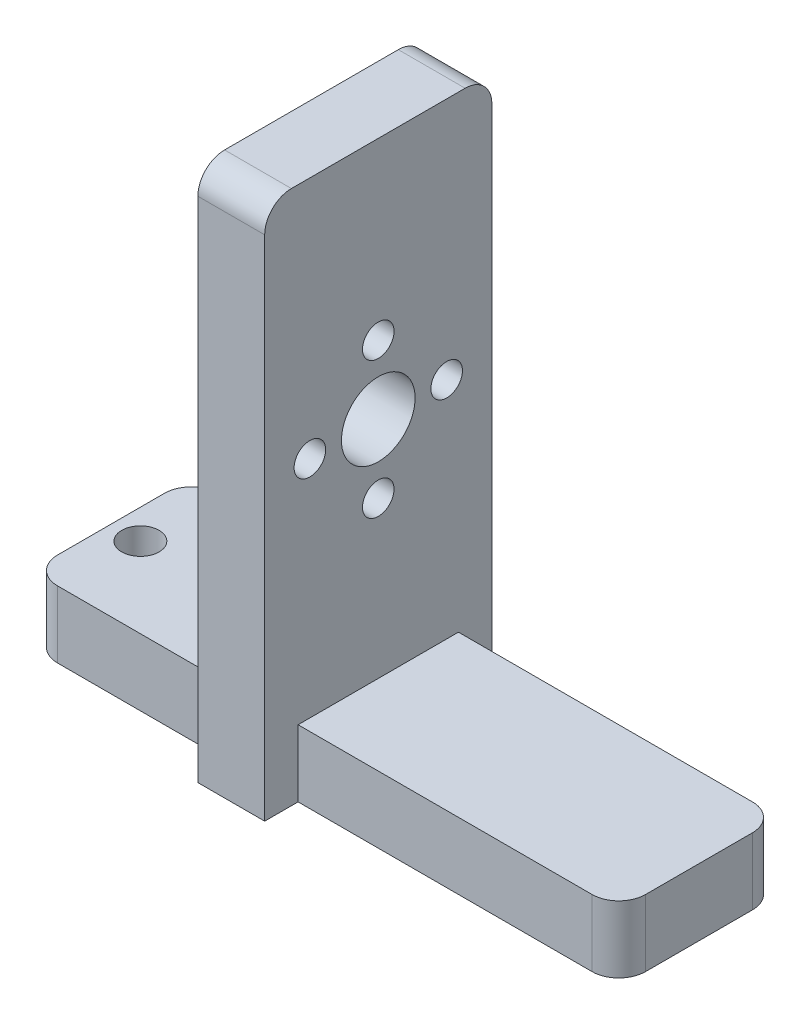
from build123d import *

# Parameters (mm, degrees)
BOSS_EXTRUDE1_DEPTH = 15.24
SKETCH5_R           = 3.5
CUT_EXTRUDE1_DEPTH  = 15.24
SKETCH6_R           = 1.778
CUT_EXTRUDE2_DEPTH  = 15.24
SKETCH8_W           = 3.175
SKETCH8_H           = 50.8
BOSS_EXTRUDE2_DEPTH = 6.35
SKETCH7_R           = 1.5
CUT_EXTRUDE3_DEPTH  = 6.35
CIRPATTERN1_COUNT   = 4
FILLET1_R           = 2.54


with BuildPart() as part:
    # Sketch2 → Boss-Extrude1 (new body)
    with BuildSketch(Plane.XY):
        Polygon((-27.94, 0), (27.94, 0), (27.94, 6.35), (-2.54, 6.35), (-2.54, 50.8), (-8.89, 50.8), (-8.89, 6.35), (-27.94, 6.35), align=None)
    extrude(amount=BOSS_EXTRUDE1_DEPTH)

    # Sketch5 → Cut-Extrude1 (cut)
    with BuildSketch(Plane.ZY.offset(8.89)):
        with Locations((7.62, 27.686)):
            Circle(SKETCH5_R)
    extrude(amount=-CUT_EXTRUDE1_DEPTH, mode=Mode.SUBTRACT)

    # Sketch6 → Cut-Extrude2 (cut)
    with BuildSketch(Plane(origin=(0, 6.35, 0), x_dir=(1, 0, 0), z_dir=(0, 1, 0))):
        with Locations((-25.146, -7.62)):
            Circle(SKETCH6_R)
        with Locations((-15.24, -7.62)):
            Circle(SKETCH6_R)
    extrude(amount=-CUT_EXTRUDE2_DEPTH, mode=Mode.SUBTRACT)

    # Sketch8 → Boss-Extrude2 (add)
    with BuildSketch(Plane.ZY.offset(8.89)):
        with Locations((-1.5875, 25.4)):
            Rectangle(SKETCH8_W, SKETCH8_H)
        with Locations((16.8275, 25.4)):
            Rectangle(SKETCH8_W, SKETCH8_H)
    extrude(amount=-BOSS_EXTRUDE2_DEPTH)

    # Sketch7 → Cut-Extrude3 (cut)
    with BuildSketch(Plane.ZY.offset(8.89)):
        with Locations((7.62, 34.186)):
            Circle(SKETCH7_R)
    cut_extrude3 = extrude(amount=-CUT_EXTRUDE3_DEPTH, mode=Mode.SUBTRACT)

    # CirPattern1: Cut-Extrude3 ×4 about axis
    cirpattern1_axis = Axis((0, 27.686, 7.62), (1, 0, 0))
    for i in range(1, CIRPATTERN1_COUNT):
        add(cut_extrude3.rotate(cirpattern1_axis, i * 360 / CIRPATTERN1_COUNT), mode=Mode.SUBTRACT)

    # Fillet1
    fillet1_edges = [part.edges().sort_by_distance(p)[0] for p in [
        (27.94, 3.175, 0),
        (-27.94, 3.175, 0),
        (27.94, 3.175, 15.24),
        (-5.715, 50.8, -3.175),
        (-27.94, 3.175, 15.24),
        (-5.715, 50.8, 18.415),
    ]]
    fillet(fillet1_edges, radius=FILLET1_R)


solid = part.part
